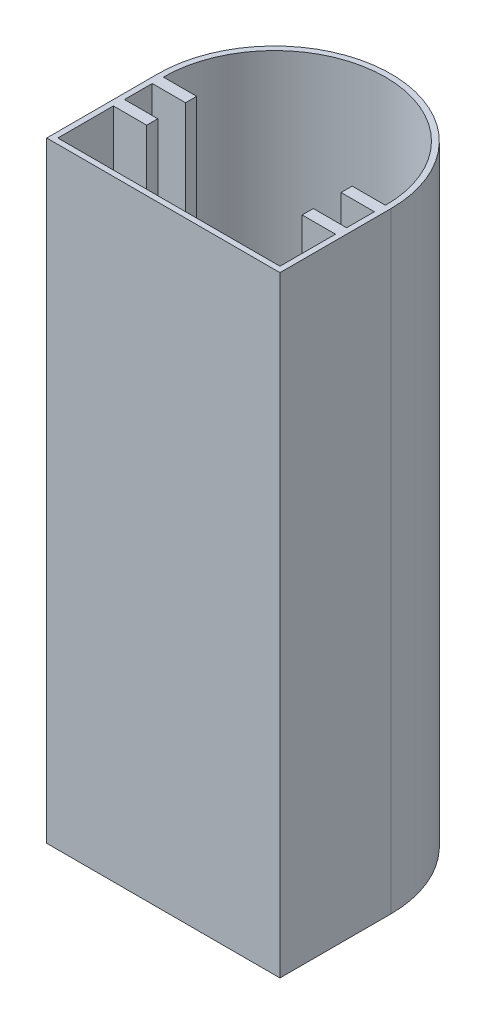
from build123d import *

# Parameters (mm, degrees)
BOSS_EXTRUDE1_DEPTH = 110
CUT_EXTRUDE1_DEPTH  = 109
SKETCH3_R           = 3.375
CUT_EXTRUDE2_DEPTH  = 5


with BuildPart() as part:
    # Sketch1 → Boss-Extrude1 (new body)
    with BuildSketch(Plane(origin=(0, 0, 0), x_dir=(1, 0, 0), z_dir=(0, 1, 0))):
        with BuildLine():
            Line((-40.883093525, -1.707733813), (1.116906475, -1.707733813))
            Line((1.116906475, -1.707733813), (1.116906475, 18.292266187))
            ThreePointArc((1.116906475, 18.292266187), (-19.883093525, 39.292266187), (-40.883093525, 18.292266187))
            Line((-40.883093525, 18.292266187), (-40.883093525, -1.707733813))
        make_face()
    extrude(amount=BOSS_EXTRUDE1_DEPTH)

    # Sketch2 → Cut-Extrude1 (cut)
    with BuildSketch(Plane(origin=(0, 110, 0), x_dir=(1, 0, 0), z_dir=(0, 1, 0))):
        with BuildLine():
            Line((-39.883093525, 16.292266187), (-39.883093525, 11.292266187))
            Line((-39.883093525, 11.292266187), (-33.883093525, 11.292266187))
            Line((-33.883093525, 11.292266187), (-33.883093525, 9.292266187))
            Line((-33.883093525, 9.292266187), (-39.883093525, 9.292266187))
            Line((-39.883093525, 9.292266187), (-39.883093525, -0.707733813))
            Line((-39.883093525, -0.707733813), (0.116906475, -0.707733813))
            Line((0.116906475, -0.707733813), (0.116906475, 9.292266187))
            Line((0.116906475, 9.292266187), (-5.883093525, 9.292266187))
            Line((-5.883093525, 9.292266187), (-5.883093525, 11.292266187))
            Line((-5.883093525, 11.292266187), (0.116906475, 11.292266187))
            Line((0.116906475, 11.292266187), (0.116906475, 16.292266187))
            Line((0.116906475, 16.292266187), (-5.883093525, 16.292266187))
            Line((-5.883093525, 16.292266187), (-5.883093525, 18.292266187))
            Line((-5.883093525, 18.292266187), (0.116906475, 18.292266187))
            ThreePointArc((0.116906475, 18.292266187), (-19.883093525, 38.292266187), (-39.883093525, 18.292266187))
            Line((-39.883093525, 18.292266187), (-33.883093525, 18.292266187))
            Line((-33.883093525, 18.292266187), (-33.883093525, 16.292266187))
            Line((-33.883093525, 16.292266187), (-39.883093525, 16.292266187))
        make_face()
    extrude(amount=-CUT_EXTRUDE1_DEPTH, mode=Mode.SUBTRACT)

    # Sketch3 → Cut-Extrude2 (cut)
    with BuildSketch(Plane.ZY.offset(40.883093525)):
        with Locations((-4.958932854, 55)):
            Circle(SKETCH3_R)
    extrude(amount=-CUT_EXTRUDE2_DEPTH, mode=Mode.SUBTRACT)


solid = part.part
